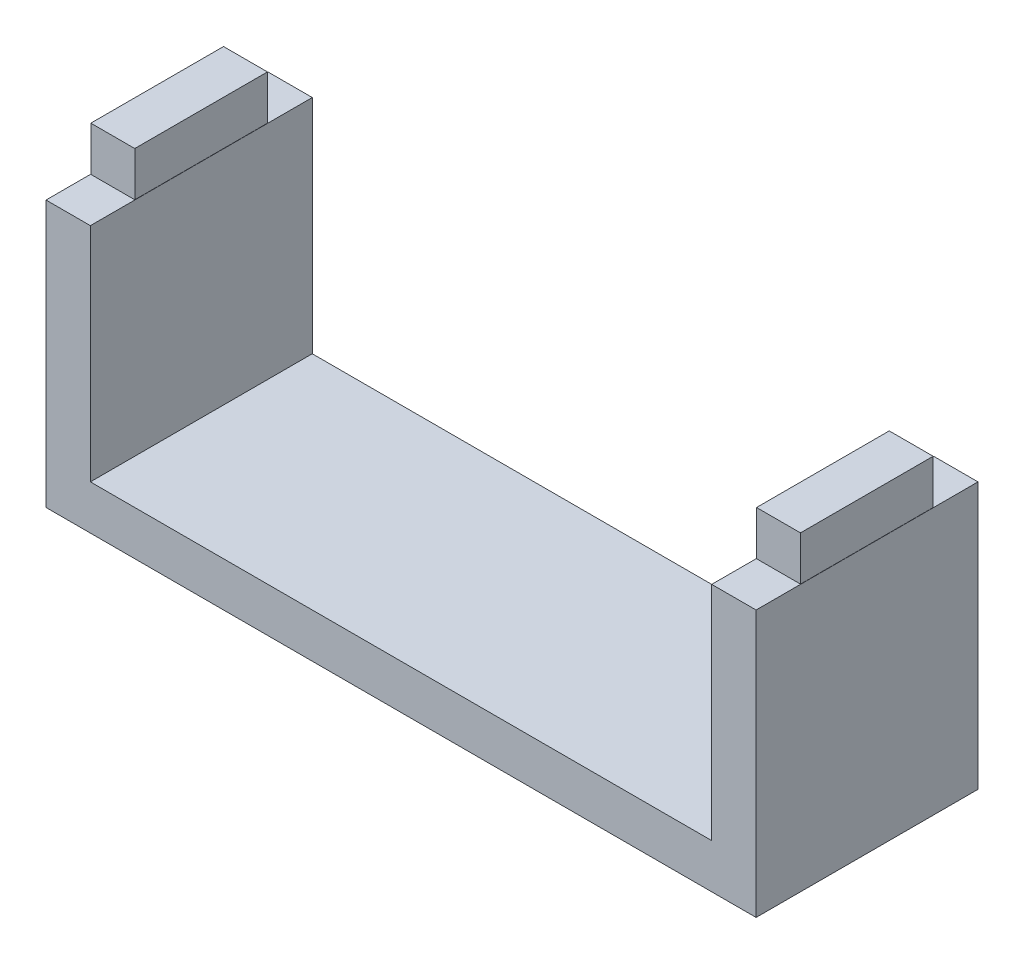
from build123d import *

# Parameters (mm, degrees)
SKETCH1_W           = 160
SKETCH1_H           = 50
BOSS_EXTRUDE1_DEPTH = 10
SKETCH2_W           = 10
SKETCH2_H           = 50
BOSS_EXTRUDE2_DEPTH = 50
SKETCH3_W           = 9.9
SKETCH3_H           = 29.9
BOSS_EXTRUDE3_DEPTH = 10


with BuildPart() as part:
    # Sketch1 → Boss-Extrude1 (new body)
    with BuildSketch(Plane(origin=(0, 0, 0), x_dir=(1, 0, 0), z_dir=(0, 1, 0))):
        Rectangle(SKETCH1_W, SKETCH1_H)
    extrude(amount=BOSS_EXTRUDE1_DEPTH)

    # Sketch2 → Boss-Extrude2 (add)
    with BuildSketch(Plane(origin=(0, 10, 0), x_dir=(1, 0, 0), z_dir=(0, 1, 0))):
        with Locations((-75, 0)):
            Rectangle(SKETCH2_W, SKETCH2_H)
        with Locations((75, 0)):
            Rectangle(SKETCH2_W, SKETCH2_H)
    extrude(amount=BOSS_EXTRUDE2_DEPTH)

    # Sketch3 → Boss-Extrude3 (add)
    with BuildSketch(Plane(origin=(0, 60, 0), x_dir=(1, 0, 0), z_dir=(0, 1, 0))):
        with Locations((-75, 0)):
            Rectangle(SKETCH3_W, SKETCH3_H)
        with Locations((75, 0)):
            Rectangle(SKETCH3_W, SKETCH3_H)
    extrude(amount=BOSS_EXTRUDE3_DEPTH)


solid = part.part
